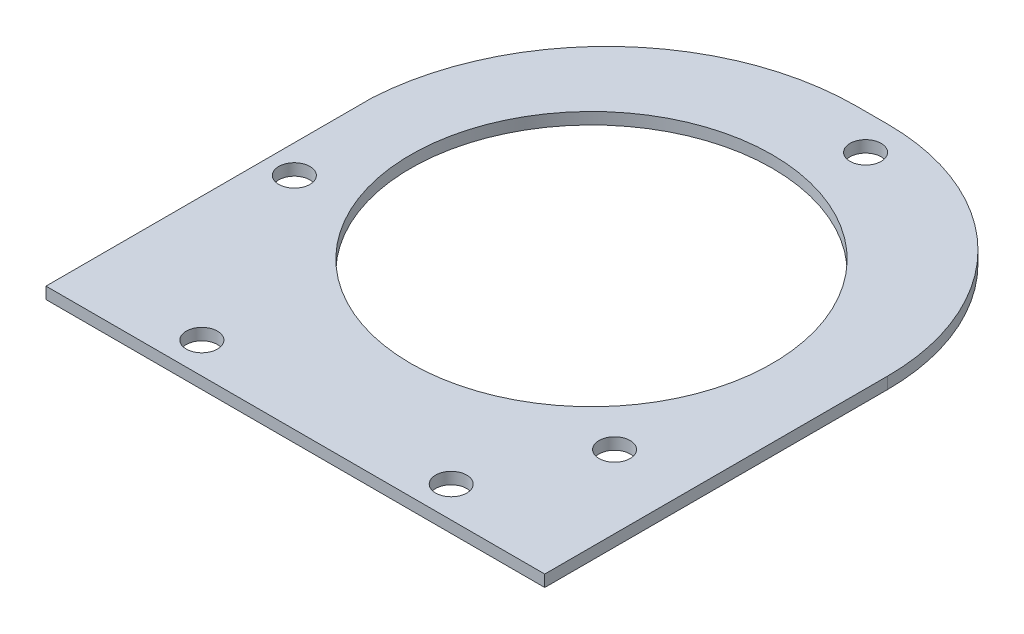
from build123d import *

# Parameters (mm, degrees)
SKETCH1_R           = 73.66
SKETCH1_R_2         = 6.35
BOSS_EXTRUDE1_DEPTH = 4.7625


with BuildPart() as part:
    # Sketch1 → Boss-Extrude1 (new body)
    with BuildSketch(Plane(origin=(0, 0, 0), x_dir=(1, 0, 0), z_dir=(0, 1, 0))):
        with BuildLine():
            Line((12.7, 114.3), (0, 114.3))
            ThreePointArc((0, 114.3), (-69.761055355, 86.634356609), (-101.6, 18.676470588))
            Line((-101.6, 18.676470588), (-101.6, -114.3))
            Line((-101.6, -114.3), (101.6, -114.3))
            Line((101.6, -114.3), (101.6, 25.4))
            ThreePointArc((101.6, 25.4), (75.561792847, 88.261792847), (12.7, 114.3))
        make_face()
        with Locations((0, 6.35)):
            Circle(SKETCH1_R, mode=Mode.SUBTRACT)
        with Locations((-90.060644326, -24.660366712)):
            Circle(SKETCH1_R_2, mode=Mode.SUBTRACT)
        with Locations((-50.8, -101.6)):
            Circle(SKETCH1_R_2, mode=Mode.SUBTRACT)
        with Locations((50.8, -101.6)):
            Circle(SKETCH1_R_2, mode=Mode.SUBTRACT)
        with Locations((18.17455681, 99.849989223)):
            Circle(SKETCH1_R_2, mode=Mode.SUBTRACT)
        with Locations((71.886087516, -56.139622511)):
            Circle(SKETCH1_R_2, mode=Mode.SUBTRACT)
    extrude(amount=BOSS_EXTRUDE1_DEPTH)


solid = part.part
